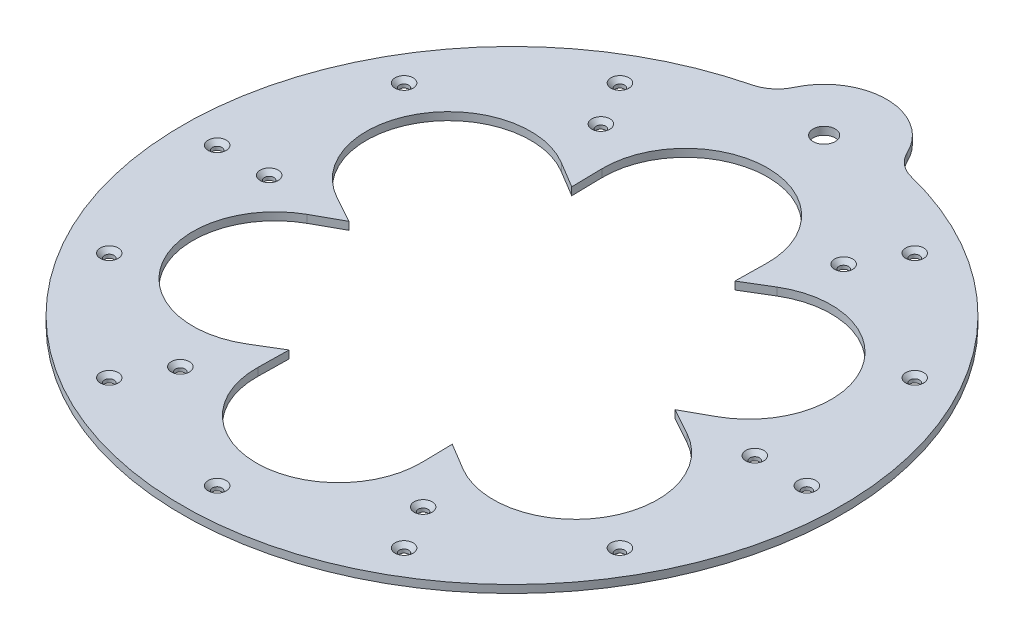
from build123d import *

# Parameters (mm, degrees)
BOSS_EXTRUDE3_DEPTH = 4.5
CIRPATTERN1_COUNT   = 12
CIRPATTERN2_COUNT   = 6
SKETCH11_R          = 6.35
CUT_EXTRUDE1_DEPTH  = 10


with BuildPart() as part:
    # Sketch5 → Boss-Extrude3 (new body)
    with BuildSketch(Plane(origin=(0, 0, 0), x_dir=(1, 0, 0), z_dir=(0, 1, 0))):
        with BuildLine():
            ThreePointArc((-45.876558414, 184.378256278), (0.010243817, -189.999999724), (45.856676704, 184.383202059))
            ThreePointArc((45.856676704, 184.383202059), (37.985823171, 188.339968607), (32.578557994, 195.294666309))
            ThreePointArc((32.578557994, 195.294666309), (-0.011645544, 215.998911827), (-32.599616361, 195.291152239))
            ThreePointArc((-32.599616361, 195.291152239), (-38.006131584, 188.335871514), (-45.876558414, 184.378256278))
        make_face()
        with BuildLine():
            Line((-47.367120943, -99.136010081), (-47.045154091, -81.484597135))
            Line((-47.045154091, -81.484597135), (-62.170742689, -90.589135081))
            ThreePointArc((-62.170742689, -90.589135081), (-127.630493883, -73.6875), (-109.537863632, -8.546875))
            Line((-109.537863632, -8.546875), (-94.090308181, 0))
            Line((-94.090308181, 0), (-109.537863632, 8.546875))
            ThreePointArc((-109.537863632, 8.546875), (-127.630493883, 73.6875), (-62.170742689, 90.589135081))
            Line((-62.170742689, 90.589135081), (-47.045154091, 81.484597135))
            Line((-47.045154091, 81.484597135), (-47.367120943, 99.136010081))
            ThreePointArc((-47.367120943, 99.136010081), (0, 147.375), (47.367120943, 99.136010081))
            Line((47.367120943, 99.136010081), (47.045154091, 81.484597135))
            Line((47.045154091, 81.484597135), (62.170742689, 90.589135081))
            ThreePointArc((62.170742689, 90.589135081), (127.630493883, 73.6875), (109.537863632, 8.546875))
            Line((109.537863632, 8.546875), (94.090308181, 0))
            Line((94.090308181, 0), (109.537863632, -8.546875))
            ThreePointArc((109.537863632, -8.546875), (127.630493883, -73.6875), (62.170742689, -90.589135081))
            Line((62.170742689, -90.589135081), (47.045154091, -81.484597135))
            Line((47.045154091, -81.484597135), (47.367120943, -99.136010081))
            ThreePointArc((47.367120943, -99.136010081), (0, -147.375), (-47.367120943, -99.136010081))
        make_face(mode=Mode.SUBTRACT)
    extrude(amount=-BOSS_EXTRUDE3_DEPTH)

    # Sketch7 → CSK for M5 Flat Head Machine Screw1 (revolve, cut)
    with BuildSketch(Plane(origin=(-170, 0, 0), x_dir=(0, 0, 1), z_dir=(1, 0, 0))):
        Polygon((0, 0), (0, 4.5), (2.75, 4.5), (2.75, 2.45), (5.2, 0), align=None)
    csk_for_m5_flat_head_machine_screw1 = revolve(axis=Axis((-170, 6.35, 0), (0, -1, 0)), mode=Mode.SUBTRACT)

    # CirPattern1: CSK for M5 Flat Head Machine Screw1 ×12 about axis, 1 skipped
    cirpattern1_axis = Axis((0, 0, 0), (0, 1, 0))
    add([csk_for_m5_flat_head_machine_screw1.rotate(cirpattern1_axis, i * 360 / CIRPATTERN1_COUNT) for i in range(1, CIRPATTERN1_COUNT) if i not in (9,)], mode=Mode.SUBTRACT)

    # Sketch9 → CSK for M5 Flat Head Machine Screw2 (revolve, cut)
    with BuildSketch(Plane(origin=(-140, 0, 0), x_dir=(0, 0, 1), z_dir=(1, 0, 0))):
        Polygon((0, 0), (0, 4.5), (2.75, 4.5), (2.75, 2.45), (5.2, 0), align=None)
    csk_for_m5_flat_head_machine_screw2 = revolve(axis=Axis((-140, 6.35, 0), (0, -1, 0)), mode=Mode.SUBTRACT)

    # CirPattern2: CSK for M5 Flat Head Machine Screw2 ×6 about axis
    cirpattern2_axis = Axis((0, 0, 0), (0, 1, 0))
    for i in range(1, CIRPATTERN2_COUNT):
        add(csk_for_m5_flat_head_machine_screw2.rotate(cirpattern2_axis, i * 360 / CIRPATTERN2_COUNT), mode=Mode.SUBTRACT)

    # Sketch11 → Cut-Extrude1 (cut)
    with BuildSketch(Plane(origin=(0, 0, 0), x_dir=(1, 0, 0), z_dir=(0, 1, 0))):
        with Locations((-0.009704669, 179.999999411)):
            Circle(SKETCH11_R)
    extrude(amount=-CUT_EXTRUDE1_DEPTH, mode=Mode.SUBTRACT)


solid = part.part
